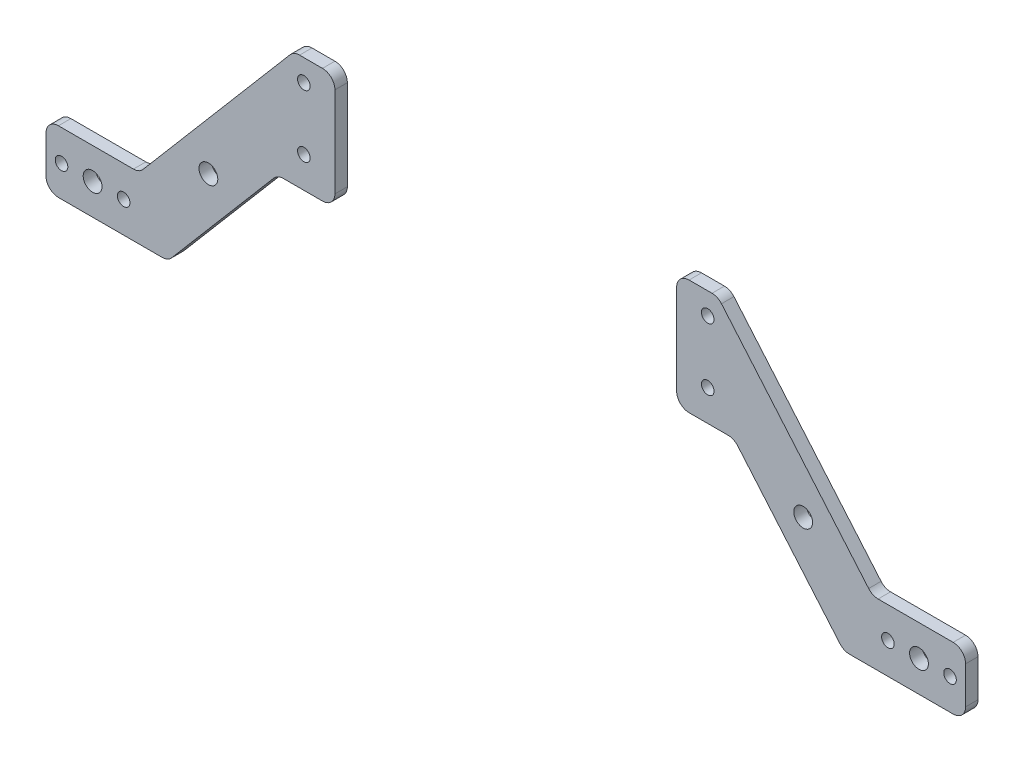
from build123d import *

# Parameters (mm, degrees)
SKETCH_1_R          = 3.025
SKETCH_1_R_2        = 2.025
EXTRUDE_1_DEPTH     = 4
SKETCH_2_W          = 79
SKETCH_2_H          = 36
CUT_EXTRUDE_1_DEPTH = 4
FILLET_1_R          = 4
SKETCH_3_W          = 110
SKETCH_3_H          = 3
SKETCH_3_H_2        = 34
CUT_EXTRUDE_2_DEPTH = 10
FILLET_2_R          = 4
FILLET_3_R          = 4


with BuildPart() as part:
    # 草图1 → 凸台-拉伸1 (new body)
    with BuildSketch(Plane.XY):
        with BuildLine():
            Line((-68.235415063, 17), (-118, -41.5))
            Line((-118, -41.5), (-148, -41.5))
            Line((-148, -41.5), (-148, -61.5))
            Line((-148, -61.5), (-108.755956962, -61.5))
            Line((-108.755956962, -61.5), (-73.45287534, -20))
            Line((-73.45287534, -20), (73.45287534, -20))
            Line((73.45287534, -20), (108.755956962, -61.5))
            Line((108.755956962, -61.5), (148, -61.5))
            Line((148, -61.5), (148, -41.5))
            Line((148, -41.5), (118, -41.5))
            Line((118, -41.5), (68.235415063, 17))
            Line((68.235415063, 17), (49.462300945, 17))
            ThreePointArc((49.462300945, 17), (47.5, 14.475), (45.537699055, 17))
            Line((45.537699055, 17), (-45.537699055, 17))
            ThreePointArc((-45.537699055, 17), (-47.5, 14.475), (-49.462300945, 17))
            Line((-49.462300945, 17), (-68.235415063, 17))
        make_face()
        with Locations((-95.72643767, -30.75)):
            Circle(SKETCH_1_R, mode=Mode.SUBTRACT)
        with Locations((95.72643767, -30.75)):
            Circle(SKETCH_1_R, mode=Mode.SUBTRACT)
        with Locations((-65, -10)):
            Circle(SKETCH_1_R_2, mode=Mode.SUBTRACT)
        with Locations((-47.5, -8.5)):
            Circle(SKETCH_1_R_2, mode=Mode.SUBTRACT)
        with Locations((-65, 10)):
            Circle(SKETCH_1_R_2, mode=Mode.SUBTRACT)
        with Locations((47.5, -8.5)):
            Circle(SKETCH_1_R_2, mode=Mode.SUBTRACT)
        with Locations((65, -10)):
            Circle(SKETCH_1_R_2, mode=Mode.SUBTRACT)
        with Locations((65, 10)):
            Circle(SKETCH_1_R_2, mode=Mode.SUBTRACT)
        with Locations((-123, -51.5)):
            Circle(SKETCH_1_R_2, mode=Mode.SUBTRACT)
        with Locations((-143, -51.5)):
            Circle(SKETCH_1_R_2, mode=Mode.SUBTRACT)
        with Locations((-133, -51.5)):
            Circle(SKETCH_1_R, mode=Mode.SUBTRACT)
        with Locations((143, -51.5)):
            Circle(SKETCH_1_R_2, mode=Mode.SUBTRACT)
        with Locations((123, -51.5)):
            Circle(SKETCH_1_R_2, mode=Mode.SUBTRACT)
        with Locations((133, -51.5)):
            Circle(SKETCH_1_R, mode=Mode.SUBTRACT)
    extrude(amount=EXTRUDE_1_DEPTH)

    # 草图2 → 切除-拉伸1 (cut)
    with BuildSketch(Plane.XY.offset(4)):
        with Locations((0, 4)):
            Rectangle(SKETCH_2_W, SKETCH_2_H)
    extrude(amount=-CUT_EXTRUDE_1_DEPTH, mode=Mode.SUBTRACT)

    # 圆角1
    fillet_1_edges = [part.edges().sort_by_distance(p)[0] for p in [
        (39.5, -14, 2),
        (-39.5, -14, 2),
        (-148, -61.5, 2),
        (-148, -41.5, 2),
        (-118, -41.5, 2),
        (-68.235415063, 17, 2),
        (68.235415063, 17, 2),
        (118, -41.5, 2),
        (148, -41.5, 2),
        (148, -61.5, 2),
        (108.755956962, -61.5, 2),
        (73.45287534, -20, 2),
        (-73.45287534, -20, 2),
        (-108.755956962, -61.5, 2),
    ]]
    fillet(fillet_1_edges, radius=FILLET_1_R)

    # 草图3 → 切除-拉伸2 (cut)
    with BuildSketch(Plane.XY.offset(4)):
        with Locations((0, -18.5)):
            Rectangle(SKETCH_3_W, SKETCH_3_H)
        Rectangle(SKETCH_3_W, SKETCH_3_H_2)
    extrude(amount=-CUT_EXTRUDE_2_DEPTH, mode=Mode.SUBTRACT)

    # 圆角2
    fillet_2_edges = [part.edges().sort_by_distance(p)[0] for p in [
        (-55, -20, 2),
        (-55, 17, 2),
    ]]
    fillet(fillet_2_edges, radius=FILLET_2_R)

    # 圆角3
    fillet_3_edges = [part.edges().sort_by_distance(p)[0] for p in [
        (55, 17, 2),
        (55, -20, 2),
    ]]
    fillet(fillet_3_edges, radius=FILLET_3_R)


solid = part.part
